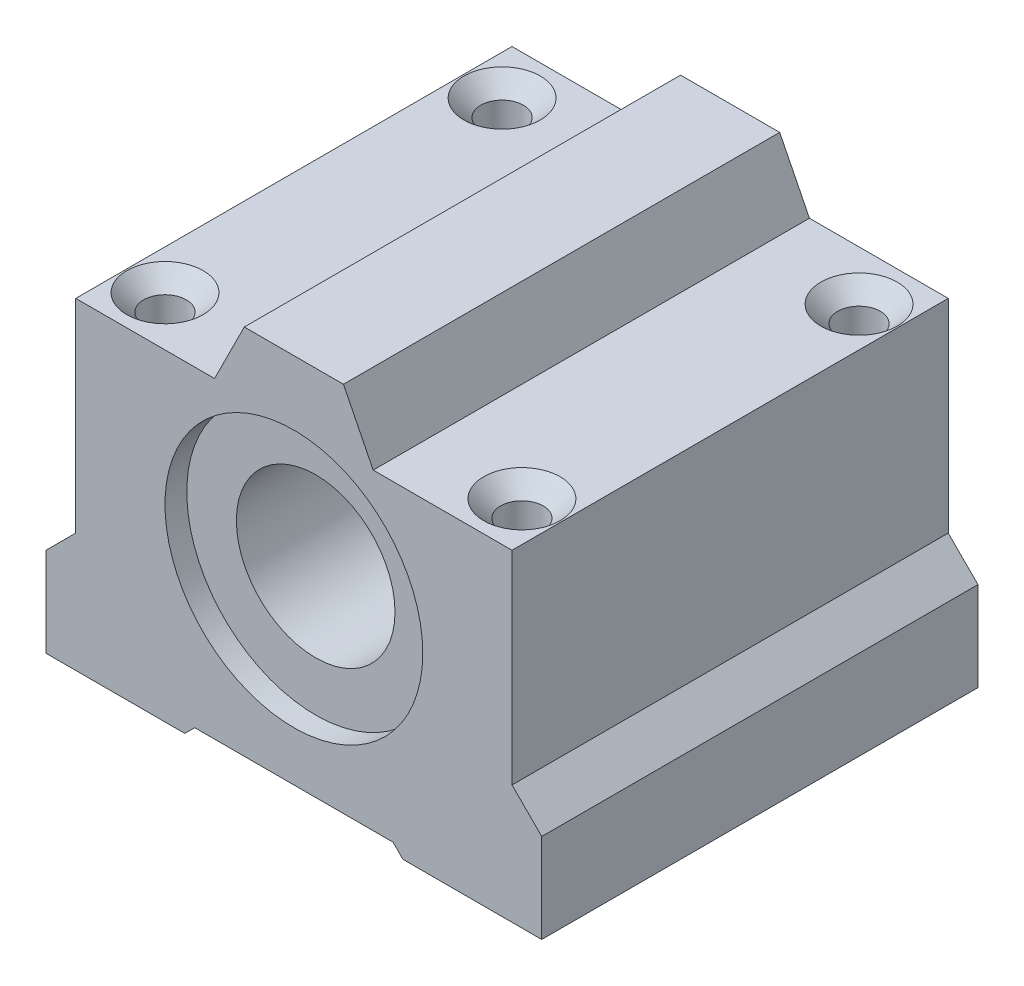
from build123d import *

# Parameters (mm, degrees)
ESBO_O1_R                                            = 8
EXTRUS_O1_DEPTH                                      = 44
ESBO_O2_R                                            = 13
EXTRUS_O2_DEPTH                                      = 2.2
ESBO_O3_R                                            = 13
EXTRUS_O3_DEPTH                                      = 2.2
ESBO_O4_R                                            = 2.15
EXTRUS_O4_DEPTH                                      = 33.5
ESCAREADO_PARA_PARAFUSO_DE_M_QUINA_COM_C_D           = 5.5
ESCAREADO_PARA_PARAFUSO_DE_M_QUINA_COM_C_DEPTH       = 12
ESCAREADO_PARA_PARAFUSO_DE_M_QUINA_COM_C_CSINK_D     = 9
ESCAREADO_PARA_PARAFUSO_DE_M_QUINA_COM_C_CSINK_ANGLE = 90
ESCAREADO_PARA_PARAFUSO_DE_M_QUINA_COM_C_TIP         = 1.652366702
CHANFRO1_SIZE                                        = 1.7


with BuildPart() as part:
    # Esboço1 → Extrusão1 (new body)
    with BuildSketch(Plane.XY):
        Polygon((-22, 13.5), (-22, -7), (-25, -10), (-25, -19), (-11, -19), (-10, -18), (10, -18), (11, -19), (25, -19), (25, -10), (22, -7), (22, 13.5), (8, 13.5), (5, 19.5), (-5, 19.5), (-8, 13.5), align=None)
        Circle(ESBO_O1_R, mode=Mode.SUBTRACT)
    extrude(amount=EXTRUS_O1_DEPTH)

    # Esboço2 → Extrusão2 (cut)
    with BuildSketch(Plane.XY.offset(44)):
        Circle(ESBO_O2_R)
    extrude(amount=-EXTRUS_O2_DEPTH, mode=Mode.SUBTRACT)

    # Esboço3 → Extrusão3 (cut)
    with BuildSketch(Plane(origin=(0, 0, 0), x_dir=(-1, 0, 0), z_dir=(0, 0, -1))):
        Circle(ESBO_O3_R)
    extrude(amount=-EXTRUS_O3_DEPTH, mode=Mode.SUBTRACT)

    # Esboço4 → Extrusão4 (cut, through all)
    with BuildSketch(Plane(origin=(0, 13.5, 0), x_dir=(1, 0, 0), z_dir=(0, 1, 0))):
        with Locations((18, -5)):
            Circle(ESBO_O4_R)
        with Locations((18, -39)):
            Circle(ESBO_O4_R)
        with Locations((-18, -5)):
            Circle(ESBO_O4_R)
        with Locations((-18, -39)):
            Circle(ESBO_O4_R)
    extrude(amount=-EXTRUS_O4_DEPTH, mode=Mode.SUBTRACT)

    # Escareado para parafuso de máquina com cabeça chata de M52
    with Locations(Plane(origin=(-18, -19, 39), x_dir=(-1, 0, 0), z_dir=(0, -1, 0))):
        with Locations((0, 0), (0, 34), (-36, 34), (-36, 0)):
            CounterSinkHole(ESCAREADO_PARA_PARAFUSO_DE_M_QUINA_COM_C_D / 2, ESCAREADO_PARA_PARAFUSO_DE_M_QUINA_COM_C_CSINK_D / 2, depth=ESCAREADO_PARA_PARAFUSO_DE_M_QUINA_COM_C_DEPTH, counter_sink_angle=ESCAREADO_PARA_PARAFUSO_DE_M_QUINA_COM_C_CSINK_ANGLE)
            with Locations((0, 0, -(ESCAREADO_PARA_PARAFUSO_DE_M_QUINA_COM_C_DEPTH + ESCAREADO_PARA_PARAFUSO_DE_M_QUINA_COM_C_TIP / 2))):  # 118° drill point
                Cone(0, ESCAREADO_PARA_PARAFUSO_DE_M_QUINA_COM_C_D / 2, ESCAREADO_PARA_PARAFUSO_DE_M_QUINA_COM_C_TIP, mode=Mode.SUBTRACT)

    # Chanfro1
    chanfro1_edges = [part.edges().sort_by_distance(p)[0] for p in [
        (15.85, 13.5, 5),
        (15.85, 13.5, 39),
        (-20.15, 13.5, 5),
        (-20.15, 13.5, 39),
    ]]
    chamfer(chanfro1_edges, length=CHANFRO1_SIZE)


solid = part.part
